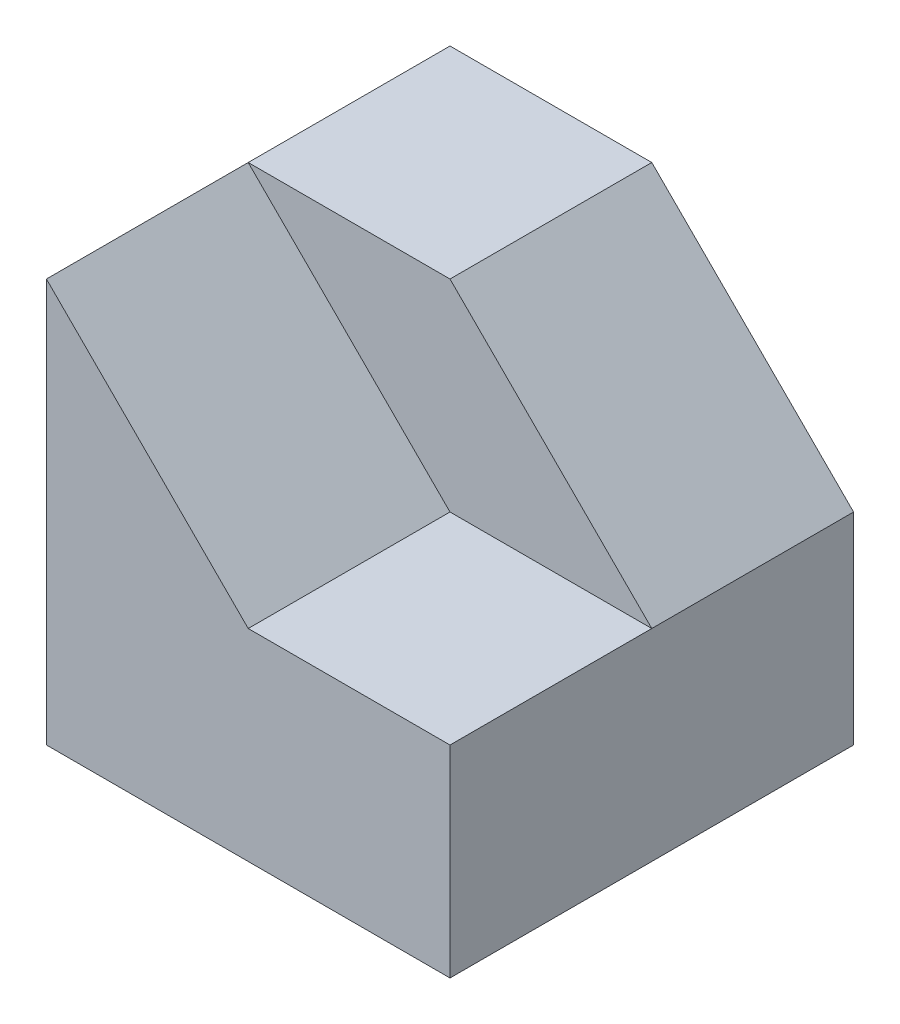
from build123d import *

# Parameters (mm, degrees)
SALIENTE_EXTRUIR1_DEPTH = 60
CORTAR_EXTRUIR1_DEPTH   = 30


with BuildPart() as part:
    # Croquis1 → Saliente-Extruir1 (new body)
    with BuildSketch(Plane.XY):
        Polygon((0, 60), (0, 0), (60, 0), (60, 30), (30, 60), align=None)
    extrude(amount=-SALIENTE_EXTRUIR1_DEPTH)

    # Croquis2 → Cortar-Extruir1 (cut)
    with BuildSketch(Plane.XY):
        Polygon((60, 30), (30, 60), (0, 60), (30, 30), align=None)
    extrude(amount=-CORTAR_EXTRUIR1_DEPTH, mode=Mode.SUBTRACT)


solid = part.part
